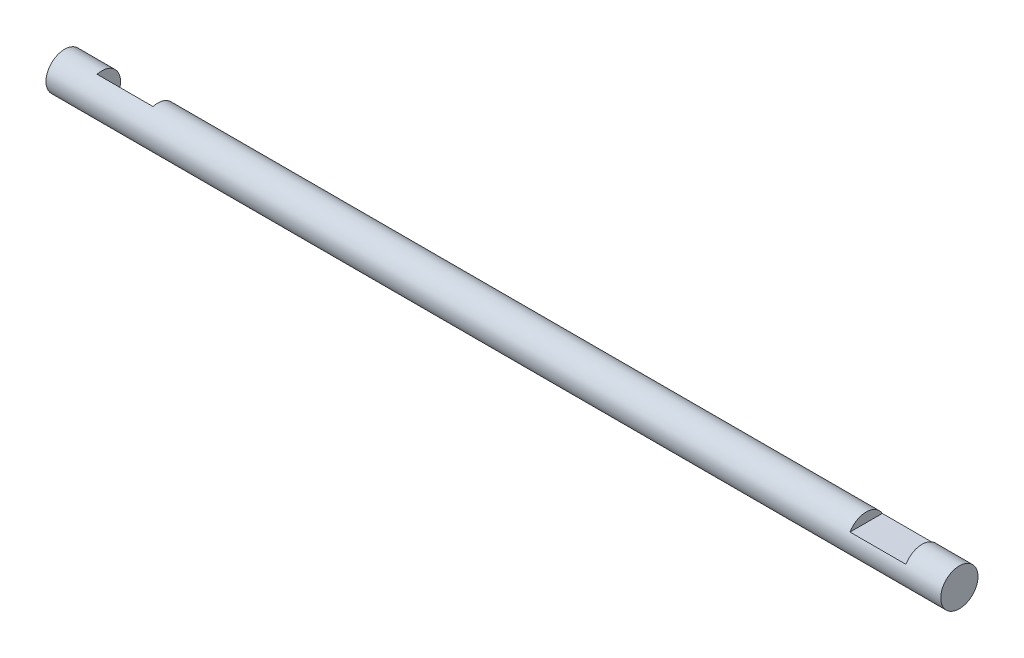
from build123d import *

# Parameters (mm, degrees)
SKETCH1_R           = 6.35
BOSS_EXTRUDE1_DEPTH = 152.4
SKETCH3_W           = 19.05
SKETCH3_H           = 12.7
CUT_EXTRUDE1_DEPTH  = 3.175
SKETCH4_W           = 19.05
SKETCH4_H           = 12.7
CUT_EXTRUDE2_DEPTH  = 3.175


with BuildPart() as part:
    # Sketch1 → Boss-Extrude1 (new body, symmetric)
    with BuildSketch(Plane(origin=(0, 0, 0), x_dir=(0, 0, -1), z_dir=(1, 0, 0))):
        Circle(SKETCH1_R)
    extrude(amount=BOSS_EXTRUDE1_DEPTH, both=True)

    # Sketch3 → Cut-Extrude1 (cut)
    with BuildSketch(Plane(origin=(0, 6.35, 0), x_dir=(1, 0, 0), z_dir=(0, 1, 0))):
        with Locations((130.175, 0)):
            Rectangle(SKETCH3_W, SKETCH3_H)
    extrude(amount=-CUT_EXTRUDE1_DEPTH, mode=Mode.SUBTRACT)

    # Sketch4 → Cut-Extrude2 (cut)
    with BuildSketch(Plane(origin=(0, 4.490128061, -4.490128061), x_dir=(1, 0, 0), z_dir=(0, -0.707106781, 0.707106781))):
        with Locations((-130.175, 0)):
            Rectangle(SKETCH4_W, SKETCH4_H)
    extrude(amount=CUT_EXTRUDE2_DEPTH, mode=Mode.SUBTRACT)


solid = part.part
